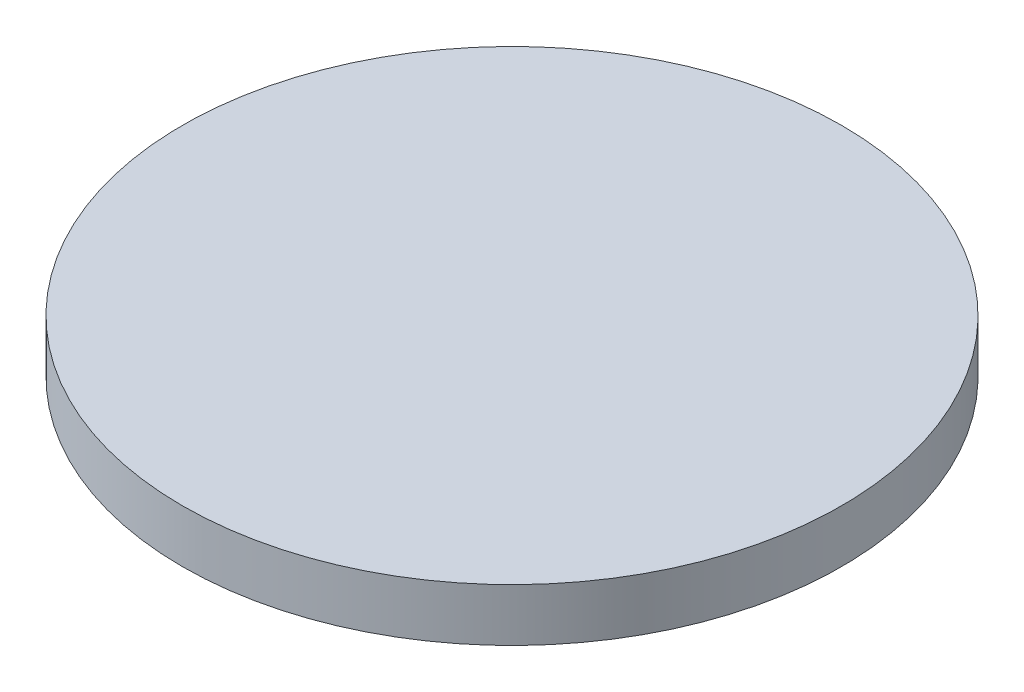
from build123d import *

# Parameters (mm, degrees)
SKETCH_1_R      = 12.5
EXTRUDE_1_DEPTH = 2


with BuildPart() as part:
    # 草图1 → 凸台-拉伸1 (new body)
    with BuildSketch(Plane(origin=(0, 0, 0), x_dir=(1, 0, 0), z_dir=(0, 1, 0))):
        with Locations(Location((0, 0, 0), (0, 0, 270))):  # turned: the seam where the file's is
            Circle(SKETCH_1_R)
    extrude(amount=EXTRUDE_1_DEPTH)


solid = part.part
